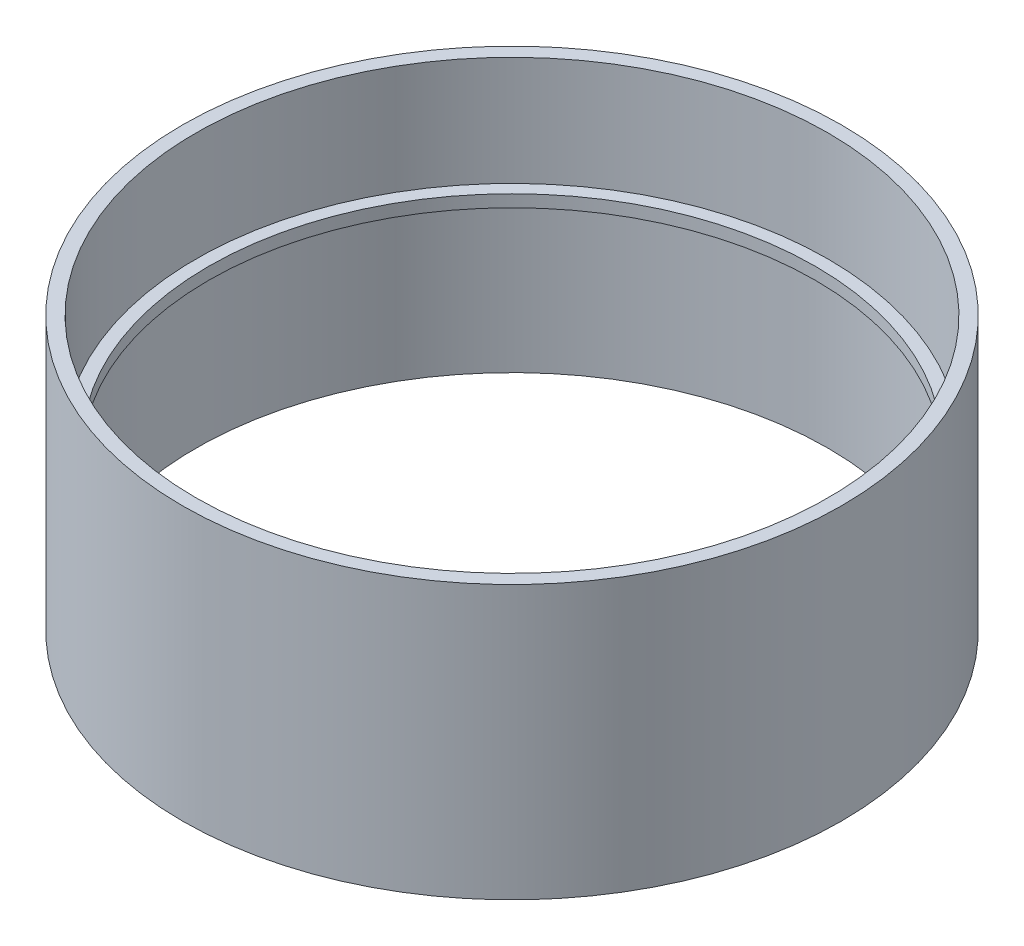
from build123d import *


with BuildPart() as part:
    # Sketch2 → Revolve1 (revolve)
    with BuildSketch(Plane.XY):
        Polygon((39.6875, 0), (39.6875, 19.05), (38.1, 19.05), (38.1, 20.574), (39.6875, 20.574), (39.6875, 34.29), (41.402, 34.29), (41.402, 0), align=None)
    revolve(axis=Axis((0, 0, 0), (0, 1, 0)))


solid = part.part
